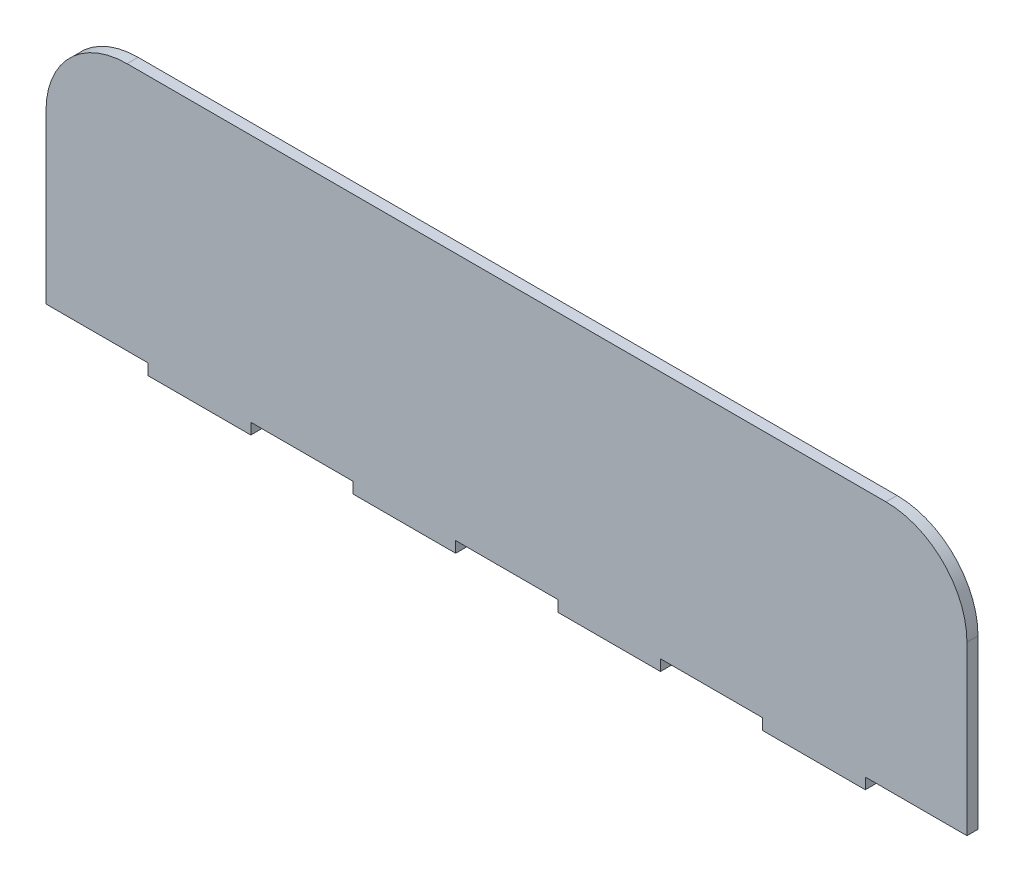
from build123d import *

# Parameters (mm, degrees)
SKETCH1_W           = 500
SKETCH1_H           = 501
BOSS_EXTRUDE1_DEPTH = 6
FILLET1_R           = 44
SKETCH2_W           = 55.5
SKETCH2_H           = 6
CUT_EXTRUDE1_DEPTH  = 10
LPATTERN1_COUNT     = 5
LPATTERN1_PITCH     = 111.2
SKETCH3_W           = 500
SKETCH3_H           = 360
CUT_EXTRUDE2_DEPTH  = 10


with BuildPart() as part:
    # Sketch1 → Boss-Extrude1 (new body)
    with BuildSketch(Plane.XY):
        with Locations((250, 250.5)):
            Rectangle(SKETCH1_W, SKETCH1_H)
    extrude(amount=BOSS_EXTRUDE1_DEPTH)

    # Fillet1
    fillet1_edges = [part.edges().sort_by_distance(p)[0] for p in [
        (0, 501, 3),
        (500, 501, 3),
        (500, 0, 3),
        (0, 0, 3),
    ]]
    fillet(fillet1_edges, radius=FILLET1_R)

    # Sketch2 → Cut-Extrude1 (cut)
    with BuildSketch(Plane(origin=(0, 0, 0), x_dir=(-1, 0, 0), z_dir=(0, 0, -1))):
        with Locations((-27.75, 363)):
            Rectangle(SKETCH2_W, SKETCH2_H)
    cut_extrude1 = extrude(amount=-CUT_EXTRUDE1_DEPTH, mode=Mode.SUBTRACT)

    # LPattern1: Cut-Extrude1 ×5
    with Locations(*[(i * LPATTERN1_PITCH, 0, 0) for i in range(1, LPATTERN1_COUNT)]):
        add(cut_extrude1, mode=Mode.SUBTRACT)

    # Sketch3 → Cut-Extrude2 (cut)
    with BuildSketch(Plane(origin=(0, 0, 0), x_dir=(-1, 0, 0), z_dir=(0, 0, -1))):
        with Locations((-250, 180)):
            Rectangle(SKETCH3_W, SKETCH3_H)
    extrude(amount=-CUT_EXTRUDE2_DEPTH, mode=Mode.SUBTRACT)


solid = part.part
